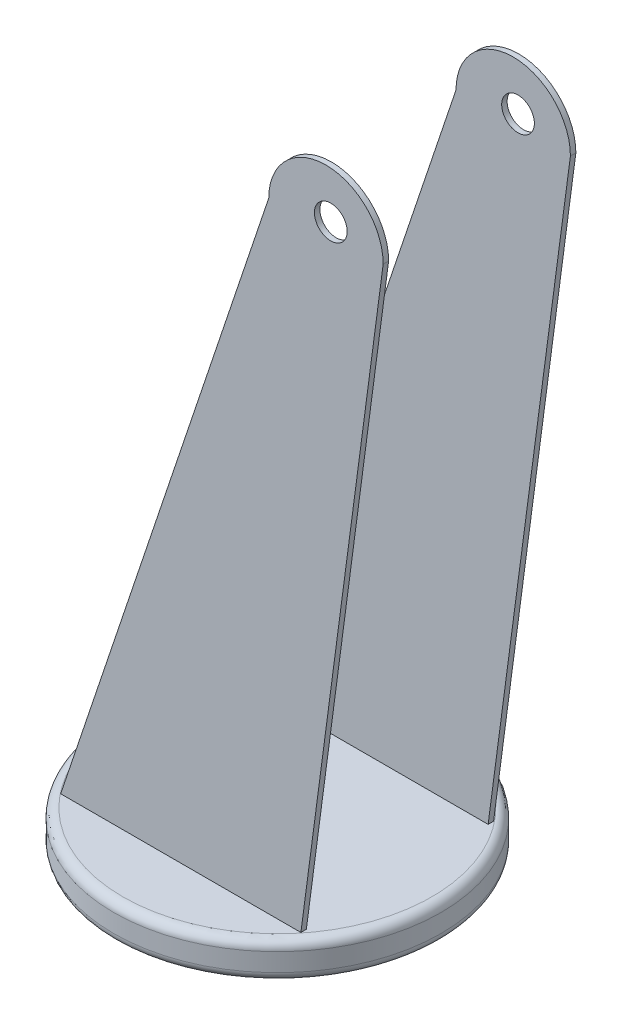
from build123d import *

# Parameters (mm, degrees)
SKETCH1_R           = 9
BOSS_EXTRUDE1_DEPTH = 2
FILLET1_R           = 0.5
SKETCH11_R          = 0.9
BOSS_EXTRUDE5_DEPTH = 0.3
SKETCH14_R          = 1
CUT_EXTRUDE1_DEPTH  = 40.252373603


with BuildPart() as part:
    # Sketch1 → Boss-Extrude1 (new body)
    with BuildSketch(Plane(origin=(0, 0, 0), x_dir=(1, 0, 0), z_dir=(0, 1, 0))):
        Circle(SKETCH1_R)
    extrude(amount=BOSS_EXTRUDE1_DEPTH)

    # Fillet1
    fillet1_edges = [part.edges().sort_by_distance(p)[0] for p in [
        (-9, 0, 0),
        (-9, 2, 0),
    ]]
    fillet(fillet1_edges, radius=FILLET1_R)

    # Sketch11 → Boss-Extrude5 (add)
    with BuildSketch(Plane.XY.offset(5)):
        with BuildLine():
            Line((6.549863489, 1.669069214), (11.12076654, 36.105315389))
            ThreePointArc((11.12076654, 36.105315389), (7.973708326, 39.252373603), (4.826650112, 36.105315389))
            Line((4.826650112, 36.105315389), (-6.731624766, 1.669069214))
            Line((-6.731624766, 1.669069214), (6.549863489, 1.669069214))
        make_face()
        with Locations((8.238882634, 36.669069214)):
            Circle(SKETCH11_R, mode=Mode.SUBTRACT)
    boss_extrude5 = extrude(amount=BOSS_EXTRUDE5_DEPTH)

    # Mirror1: Boss-Extrude5 across plane
    add(boss_extrude5.mirror(Plane.XY))

    # Sketch14 → Cut-Extrude1 (cut, through all)
    with BuildSketch(Plane.XZ):
        Circle(SKETCH14_R)
    extrude(amount=-CUT_EXTRUDE1_DEPTH, mode=Mode.SUBTRACT)


solid = part.part
